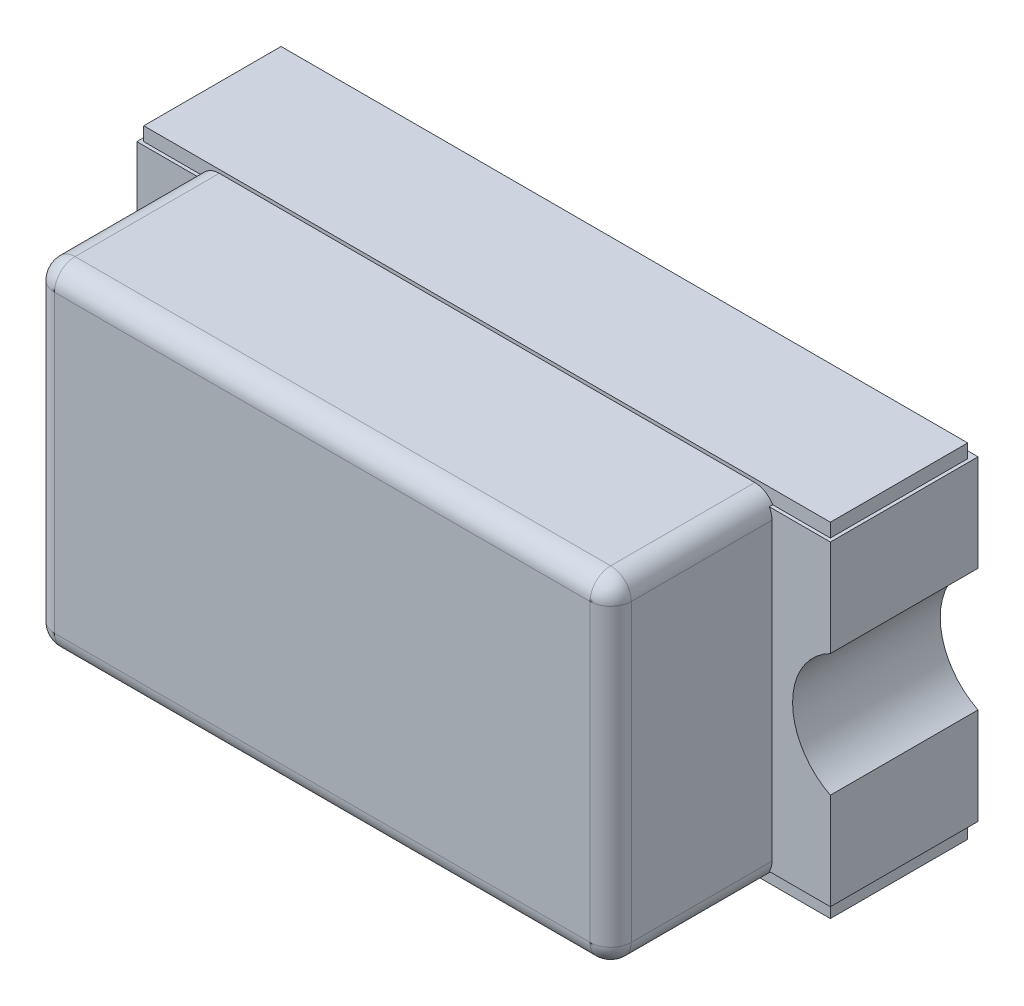
from build123d import *

# Parameters (mm, degrees)
EXTRUDE_START       = 0.01
SKETCH_2_W          = 1
SKETCH_2_H          = 0.5
EXTRUDE_1_DEPTH     = 0.2
SKETCH_3_W          = 0.205
SKETCH_3_H          = 0.46
EXTRUDE_2_DEPTH     = 0.215
EXTRUDE_START_2     = 0.2
SKETCH_4_W          = 0.84
SKETCH_4_H          = 0.49
EXTRUDE_3_DEPTH     = 0.25
FILLET_1_R          = 0.03
SKETCH_6_R          = 0.1
CUT_EXTRUDE_2_DEPTH = 0.52


with BuildPart() as part:
    # Sketch 2 → Extrude 1 (new body)
    with BuildSketch(Plane.XY.offset(EXTRUDE_START)):
        Rectangle(SKETCH_2_W, SKETCH_2_H)
    extrude(amount=EXTRUDE_1_DEPTH)

    # Sketch 3 → Extrude 2 (add)
    with BuildSketch(Plane.XY):
        with Locations((-0.4025, 0)):
            Rectangle(SKETCH_3_W, SKETCH_3_H)
        with Locations((0.4025, 0)):
            Rectangle(SKETCH_3_W, SKETCH_3_H)
    extrude(amount=EXTRUDE_2_DEPTH)

    # Sketch 4 → Extrude 3 (add)
    with BuildSketch(Plane.XY.offset(EXTRUDE_START_2)):
        Rectangle(SKETCH_4_W, SKETCH_4_H)
    extrude(amount=EXTRUDE_3_DEPTH)

    # Fillet 1
    fillet_1_edges = [part.edges().sort_by_distance(p)[0] for p in [
        (-0.42, 0.245, 0.33),
        (-0.42, 0, 0.45),
        (-0.42, -0.245, 0.33),
        (0.42, 0.245, 0.33),
        (0, 0.245, 0.45),
        (0.42, -0.245, 0.33),
        (0.42, 0, 0.45),
        (0, -0.245, 0.45),
    ]]
    fillet(fillet_1_edges, radius=FILLET_1_R)

    # Sketch 6 → Cut-Extrude 2 (cut)
    with BuildSketch(Plane.XY):
        with Locations((-0.55, 0)):
            Circle(SKETCH_6_R)
        with Locations((0.55, 0)):
            Circle(SKETCH_6_R)
    extrude(amount=CUT_EXTRUDE_2_DEPTH, mode=Mode.SUBTRACT)


solid = part.part
